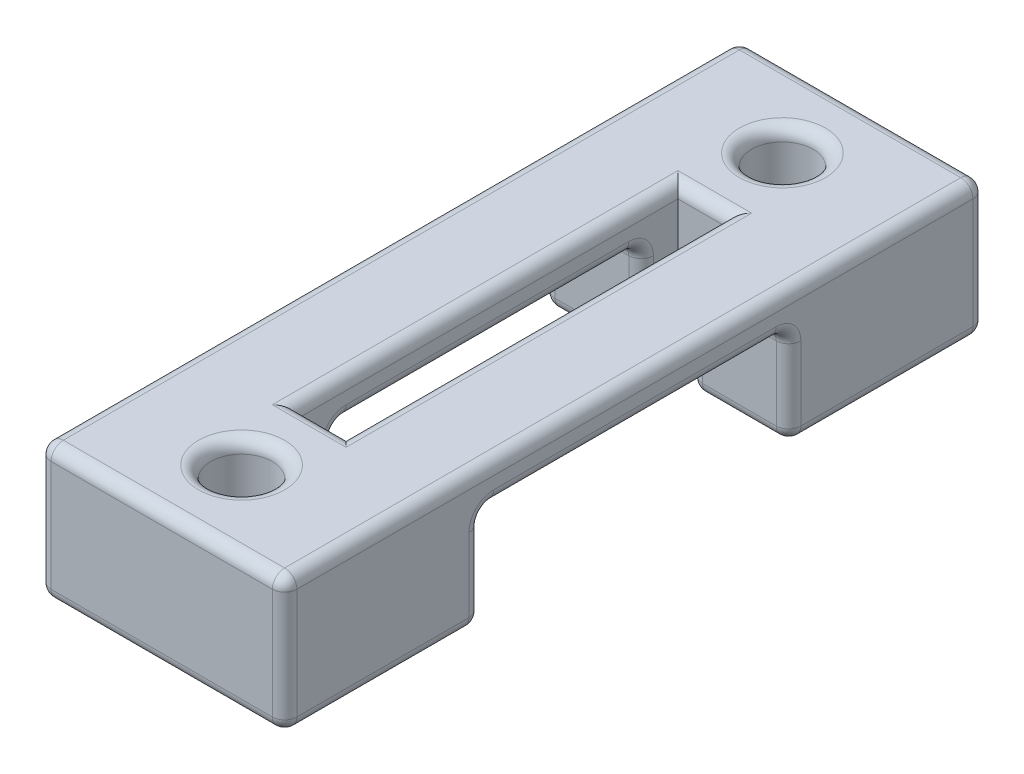
from build123d import *

# Parameters (mm, degrees)
BOSS_EXTRUDE1_DEPTH = 10
SKETCH2_W           = 2
SKETCH2_H           = 15.5
CUT_EXTRUDE1_DEPTH  = 10
SKETCH3_R           = 1.25
CUT_EXTRUDE2_DEPTH  = 10
FILLET1_R           = 0.5


with BuildPart() as part:
    # Sketch1 → Boss-Extrude1 (new body)
    with BuildSketch(Plane(origin=(0, 0, 0), x_dir=(0, 0, -1), z_dir=(1, 0, 0))):
        Polygon((-14.25, 0), (-6.25, 0), (-6.25, 4), (6.25, 4), (6.25, 0), (14.25, 0), (14.25, 5.5), (-14.25, 5.5), align=None)
    extrude(amount=BOSS_EXTRUDE1_DEPTH)

    # Sketch2 → Cut-Extrude1 (cut)
    with BuildSketch(Plane(origin=(0, 5.5, 0), x_dir=(1, 0, 0), z_dir=(0, 1, 0))):
        with Locations((5, 0)):
            Rectangle(SKETCH2_W, SKETCH2_H)
    extrude(amount=-CUT_EXTRUDE1_DEPTH, mode=Mode.SUBTRACT)

    # Sketch3 → Cut-Extrude2 (cut)
    with BuildSketch(Plane.XZ):
        with Locations((5, 11)):
            Circle(SKETCH3_R)
        with Locations((5, -11)):
            Circle(SKETCH3_R)
    extrude(amount=-CUT_EXTRUDE2_DEPTH, mode=Mode.SUBTRACT)

    # Fillet1
    fillet1_edges = [part.edges().sort_by_distance(p)[0] for p in [
        (0, 4, 0),
        (0, 2, 6.25),
        (0, 0, 10.25),
        (0, 2.75, 14.25),
        (10, 2, 6.25),
        (5, 5.5, 14.25),
        (5, 5.5, -14.25),
        (5, 0, -14.25),
        (8, 0, -6.25),
        (8, 4, -6.25),
        (8, 4, 6.25),
        (8, 0, 6.25),
        (5, 0, 14.25),
        (10, 4, 0),
        (10, 2, -6.25),
        (10, 0, -10.25),
        (2, 0, -6.25),
        (2, 4, -6.25),
        (10, 2.75, -14.25),
        (2, 4, 6.25),
        (2, 0, 6.25),
        (10, 5.5, 0),
        (4, 2, 6.25),
        (4, 0, 7),
        (4, 0, -7),
        (4, 2, -6.25),
        (4, 4, 0),
        (5, 0, -7.75),
        (6, 0, 7),
        (6, 2, 6.25),
        (6, 4, 0),
        (6, 2, -6.25),
        (6, 0, -7),
        (5, 0, 7.75),
        (4, 5.5, 0),
        (5, 5.5, 7.75),
        (6, 5.5, 0),
        (5, 5.5, -7.75),
        (10, 2.75, 14.25),
        (3.75, 5.5, 11),
        (3.75, 0, 11),
        (3.75, 5.5, -11),
        (3.75, 0, -11),
        (0, 5.5, 0),
        (10, 0, 10.25),
        (0, 2.75, -14.25),
        (0, 0, -10.25),
        (0, 2, -6.25),
    ]]
    fillet(fillet1_edges, radius=FILLET1_R)


solid = part.part
